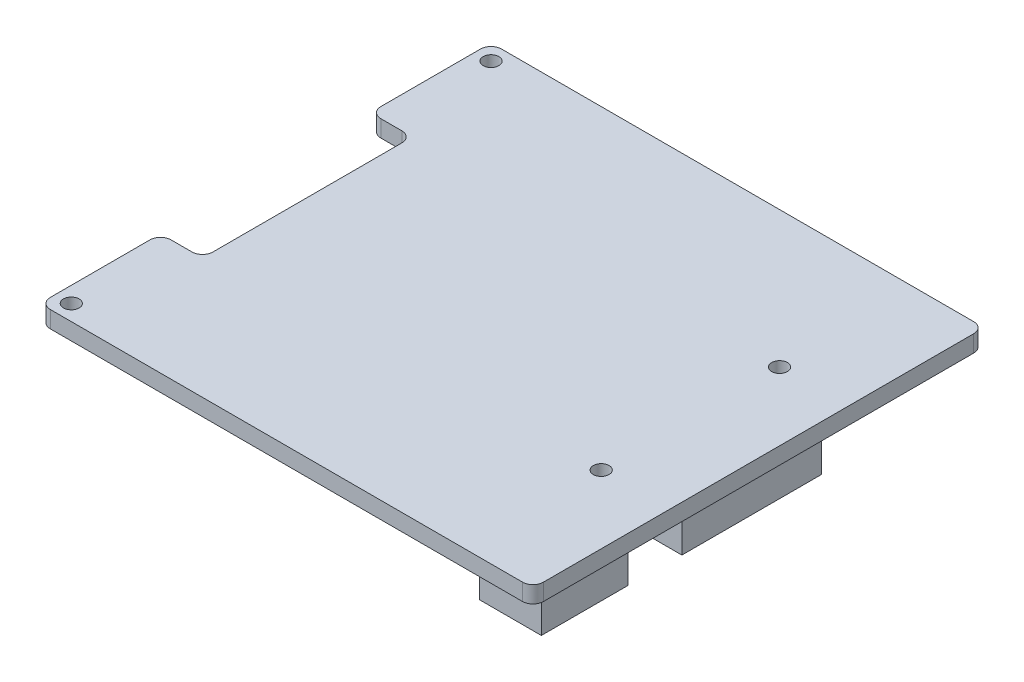
from build123d import *

# Parameters (mm, degrees)
SKETCH_1_W          = 47
SKETCH_1_H          = 43
EXTRUDE_1_DEPTH     = 1.6
SKETCH_2_R          = 0.75
CUT_EXTRUDE_1_DEPTH = 2.6
SKETCH_3_R          = 0.75
CUT_EXTRUDE_2_DEPTH = 2.6
FILLET_1_R          = 1
SKETCH_4_W          = 4
SKETCH_4_H          = 20
CUT_EXTRUDE_3_DEPTH = 2.6
FILLET_2_R          = 1
FILLET_3_R          = 1
SKETCH_5_W          = 5.069767946
SKETCH_5_H          = 34.220933634
SKETCH_5_W_2        = 5.937201646
SKETCH_5_H_2        = 13.326189681
SKETCH_5_W_3        = 5.876807137
SKETCH_5_H_3        = 8.238372911
EXTRUDE_2_DEPTH     = 3


with BuildPart() as part:
    # 草图1 → 凸台-拉伸1 (new body)
    with BuildSketch(Plane(origin=(0, 0, 0), x_dir=(1, 0, 0), z_dir=(0, 1, 0))):
        Rectangle(SKETCH_1_W, SKETCH_1_H)
    extrude(amount=EXTRUDE_1_DEPTH)

    # 草图2 → 切除-拉伸1 (cut, through all)
    with BuildSketch(Plane(origin=(0, 1.6, 0), x_dir=(1, 0, 0), z_dir=(0, 1, 0))):
        with Locations((-22, 20)):
            Circle(SKETCH_2_R)
        with Locations((-22, -20)):
            Circle(SKETCH_2_R)
    extrude(amount=-CUT_EXTRUDE_1_DEPTH, mode=Mode.SUBTRACT)

    # 草图3 → 切除-拉伸2 (cut, through all)
    with BuildSketch(Plane(origin=(0, 1.6, 0), x_dir=(1, 0, 0), z_dir=(0, 1, 0))):
        with Locations((17, 8.5)):
            Circle(SKETCH_3_R)
        with Locations((17, -8.5)):
            Circle(SKETCH_3_R)
    extrude(amount=-CUT_EXTRUDE_2_DEPTH, mode=Mode.SUBTRACT)

    # 圆角1
    fillet_1_edges = [part.edges().sort_by_distance(p)[0] for p in [
        (-23.5, 0.8, -21.5),
        (23.5, 0.8, -21.5),
        (23.5, 0.8, 21.5),
        (-23.5, 0.8, 21.5),
    ]]
    fillet(fillet_1_edges, radius=FILLET_1_R)

    # 草图4 → 切除-拉伸3 (cut, through all)
    with BuildSketch(Plane.XZ):
        with Locations((-21.5, 0)):
            Rectangle(SKETCH_4_W, SKETCH_4_H)
    extrude(amount=-CUT_EXTRUDE_3_DEPTH, mode=Mode.SUBTRACT)

    # 圆角2
    fillet_2_edges = [part.edges().sort_by_distance(p)[0] for p in [
        (-23.5, 0.8, -10),
        (-23.5, 0.8, 10),
    ]]
    fillet(fillet_2_edges, radius=FILLET_2_R)

    # 圆角3
    fillet_3_edges = [part.edges().sort_by_distance(p)[0] for p in [
        (-19.5, 0.8, 10),
        (-19.5, 0.8, -10),
    ]]
    fillet(fillet_3_edges, radius=FILLET_3_R)

    # 草图5 → 凸台-拉伸2 (add)
    with BuildSketch(Plane(origin=(0, 0, 0), x_dir=(1, 0, 0), z_dir=(0, 1, 0))):
        with Locations((-14.535975282, 0)):
            Rectangle(SKETCH_5_W, SKETCH_5_H)
        with Locations((20.296771565, -0.412263102)):
            Rectangle(SKETCH_5_W_2, SKETCH_5_H_2)
        with Locations((20.266574311, -16.287696964)):
            Rectangle(SKETCH_5_W_3, SKETCH_5_H_3)
    extrude(amount=-EXTRUDE_2_DEPTH)


solid = part.part
